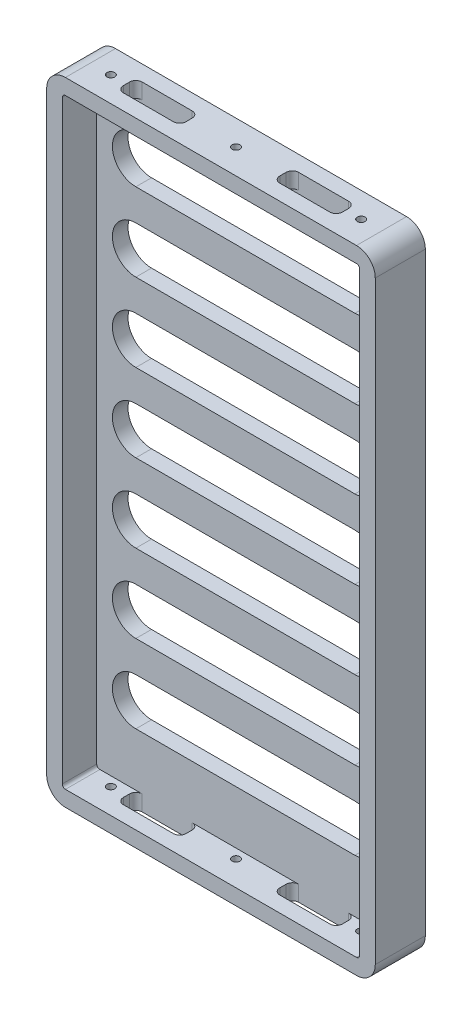
from build123d import *

# Parameters (mm, degrees)
SKETCH1_W             = 105
SKETCH1_H             = 202
BOSS_EXTRUDE1_DEPTH   = 16
SKETCH2_W             = 95
SKETCH2_H             = 192
CUT_EXTRUDE1_DEPTH    = 11
CUT_EXTRUDE2_DEPTH    = 5
LPATTERN1_COUNT       = 7
LPATTERN1_PITCH       = 25
CUT_EXTRUDE4_DEPTH    = 287
FILLET1_R             = 6
FILLET2_R             = 1
M3_TAPPED_HOLE1_D     = 2.5
M3_TAPPED_HOLE1_DEPTH = 7.5
M3_TAPPED_HOLE1_TIP   = 0.751075774
M3_TAPPED_HOLE2_D     = 2.5
M3_TAPPED_HOLE2_DEPTH = 7.5
M3_TAPPED_HOLE2_TIP   = 0.751075774


with BuildPart() as part:
    # Sketch1 → Boss-Extrude1 (new body)
    with BuildSketch(Plane.XY):
        with Locations((52.5, 101)):
            Rectangle(SKETCH1_W, SKETCH1_H)
    extrude(amount=BOSS_EXTRUDE1_DEPTH)

    # Sketch2 → Cut-Extrude1 (cut)
    with BuildSketch(Plane.XY.offset(16)):
        with Locations((52.5, 101)):
            Rectangle(SKETCH2_W, SKETCH2_H)
    extrude(amount=-CUT_EXTRUDE1_DEPTH, mode=Mode.SUBTRACT)

    # Sketch3 → Cut-Extrude2 (cut)
    with BuildSketch(Plane.XY.offset(5)):
        with BuildLine():
            Line((17.5, 187), (87.5, 187))
            ThreePointArc((87.5, 187), (95, 179.5), (87.5, 172))
            Line((87.5, 172), (17.5, 172))
            ThreePointArc((17.5, 172), (10, 179.5), (17.5, 187))
        make_face()
    cut_extrude2 = extrude(amount=-CUT_EXTRUDE2_DEPTH, mode=Mode.SUBTRACT)

    # LPattern1: Cut-Extrude2 ×7
    with Locations(*[(0, -i * LPATTERN1_PITCH, 0) for i in range(1, LPATTERN1_COUNT)]):
        add(cut_extrude2, mode=Mode.SUBTRACT)

    # Sketch5 → Cut-Extrude4 (cut)
    with BuildSketch(Plane.XZ):
        with BuildLine():
            Line((17.5, 7), (17.5, 9))
            ThreePointArc((17.5, 9), (18.085786438, 10.414213562), (19.5, 11))
            Line((19.5, 11), (35.5, 11))
            ThreePointArc((35.5, 11), (36.914213562, 10.414213562), (37.5, 9))
            Line((37.5, 9), (37.5, 7))
            ThreePointArc((37.5, 7), (36.914213562, 5.585786438), (35.5, 5))
            Line((35.5, 5), (19.5, 5))
            ThreePointArc((19.5, 5), (18.085786438, 5.585786438), (17.5, 7))
        make_face()
        with BuildLine():
            Line((87.5, 9), (87.5, 7))
            ThreePointArc((87.5, 7), (86.914213562, 5.585786438), (85.5, 5))
            Line((85.5, 5), (69.5, 5))
            ThreePointArc((69.5, 5), (68.085786438, 5.585786438), (67.5, 7))
            Line((67.5, 7), (67.5, 9))
            ThreePointArc((67.5, 9), (68.085786438, 10.414213562), (69.5, 11))
            Line((69.5, 11), (85.5, 11))
            ThreePointArc((85.5, 11), (86.914213562, 10.414213562), (87.5, 9))
        make_face()
    extrude(amount=-CUT_EXTRUDE4_DEPTH, mode=Mode.SUBTRACT)

    # Fillet1
    fillet1_edges = [part.edges().sort_by_distance(p)[0] for p in [
        (0, 202, 8),
        (105, 202, 8),
        (105, 0, 8),
        (0, 0, 8),
    ]]
    fillet(fillet1_edges, radius=FILLET1_R)

    # Fillet2
    fillet2_edges = [part.edges().sort_by_distance(p)[0] for p in [
        (100, 197, 10.5),
        (5, 197, 10.5),
        (5, 5, 10.5),
        (100, 5, 10.5),
    ]]
    fillet(fillet2_edges, radius=FILLET2_R)

    # M3 Tapped Hole1
    with Locations(Plane(origin=(92.5, 202, 8), x_dir=(0, 0, 1), z_dir=(0, 1, 0))):
        with Locations((0, 0), (0, -40), (0, -80)):
            Hole(M3_TAPPED_HOLE1_D / 2, depth=M3_TAPPED_HOLE1_DEPTH)
            with Locations((0, 0, -(M3_TAPPED_HOLE1_DEPTH + M3_TAPPED_HOLE1_TIP / 2))):  # 118° drill point
                Cone(0, M3_TAPPED_HOLE1_D / 2, M3_TAPPED_HOLE1_TIP, mode=Mode.SUBTRACT)

    # M3 Tapped Hole2
    with Locations(Plane(origin=(12.5, 0, 8), x_dir=(0, 0, -1), z_dir=(0, -1, 0))):
        with Locations((0, 0), (0, 40), (0, 80)):
            Hole(M3_TAPPED_HOLE2_D / 2, depth=M3_TAPPED_HOLE2_DEPTH)
            with Locations((0, 0, -(M3_TAPPED_HOLE2_DEPTH + M3_TAPPED_HOLE2_TIP / 2))):  # 118° drill point
                Cone(0, M3_TAPPED_HOLE2_D / 2, M3_TAPPED_HOLE2_TIP, mode=Mode.SUBTRACT)


solid = part.part
